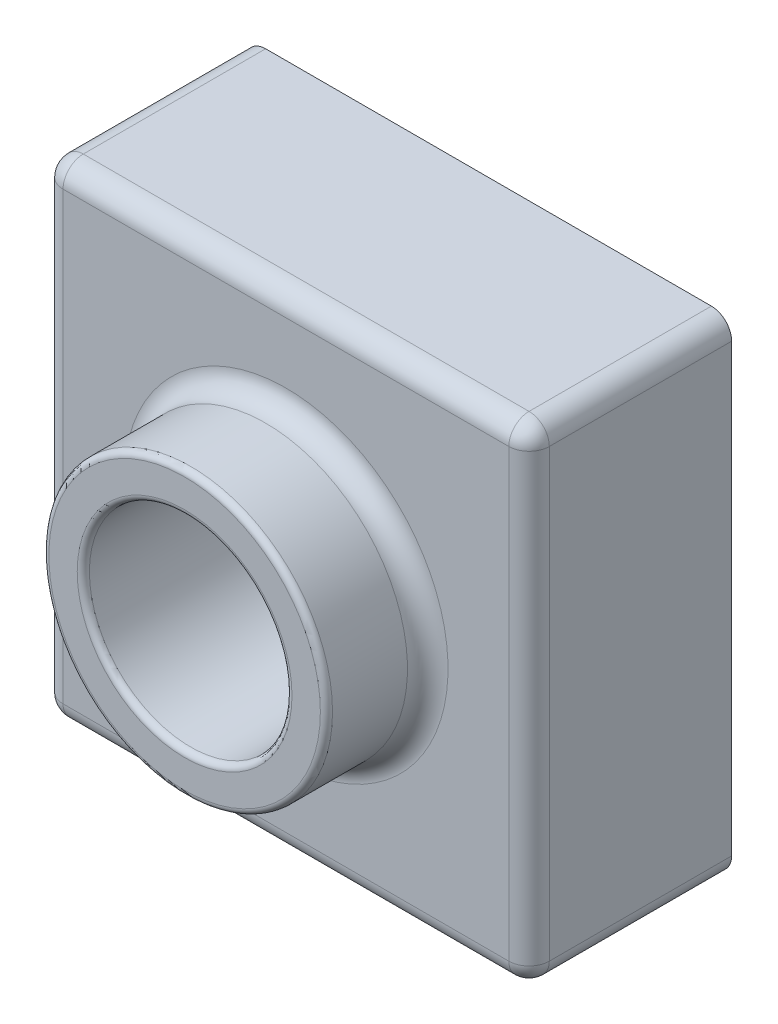
from build123d import *

# Parameters (mm, degrees)
SKETCH2_W           = 120
SKETCH2_H           = 120
BOSS_EXTRUDE1_DEPTH = 50
SKETCH4_R           = 35
BOSS_EXTRUDE2_DEPTH = 25
SKETCH6_R           = 25
CUT_EXTRUDE1_DEPTH  = 186.539753153
FILLET1_R           = 5
FILLET2_R           = 1.5
SHELL1_T            = -2


with BuildPart() as part:
    # Sketch2 → Boss-Extrude1 (new body)
    with BuildSketch(Plane.XY):
        with Locations((60, 60)):
            Rectangle(SKETCH2_W, SKETCH2_H)
    extrude(amount=BOSS_EXTRUDE1_DEPTH)

    # Sketch4 → Boss-Extrude2 (add)
    with BuildSketch(Plane.XY.offset(50)):
        with Locations(Location((60, 60, 0), (0, 0, 180))):
            Circle(SKETCH4_R)
    extrude(amount=BOSS_EXTRUDE2_DEPTH)

    # Sketch6 → Cut-Extrude1 (cut, through all)
    with BuildSketch(Plane.XY.offset(75)):
        with Locations((60, 60)):
            Circle(SKETCH6_R)
    extrude(amount=-CUT_EXTRUDE1_DEPTH, mode=Mode.SUBTRACT)

    # Fillet1
    fillet1_edges = [part.edges().sort_by_distance(p)[0] for p in [
        (120, 60, 50),
        (60, 120, 50),
        (95, 60, 50),
        (0, 60, 50),
        (60, 0, 50),
        (0, 120, 25),
        (120, 120, 25),
        (120, 0, 25),
        (0, 0, 25),
    ]]
    fillet(fillet1_edges, radius=FILLET1_R)

    # Fillet2
    fillet2_edges = [part.edges().sort_by_distance(p)[0] for p in [
        (95, 60, 75),
        (35, 60, 75),
    ]]
    fillet(fillet2_edges, radius=FILLET2_R)

    # Shell1
    shell1_openings = [part.faces().sort_by_distance(p)[0] for p in [
        (60, 1.697056275, 0),
    ]]
    offset(amount=SHELL1_T, openings=shell1_openings, kind=Kind.INTERSECTION)


solid = part.part
